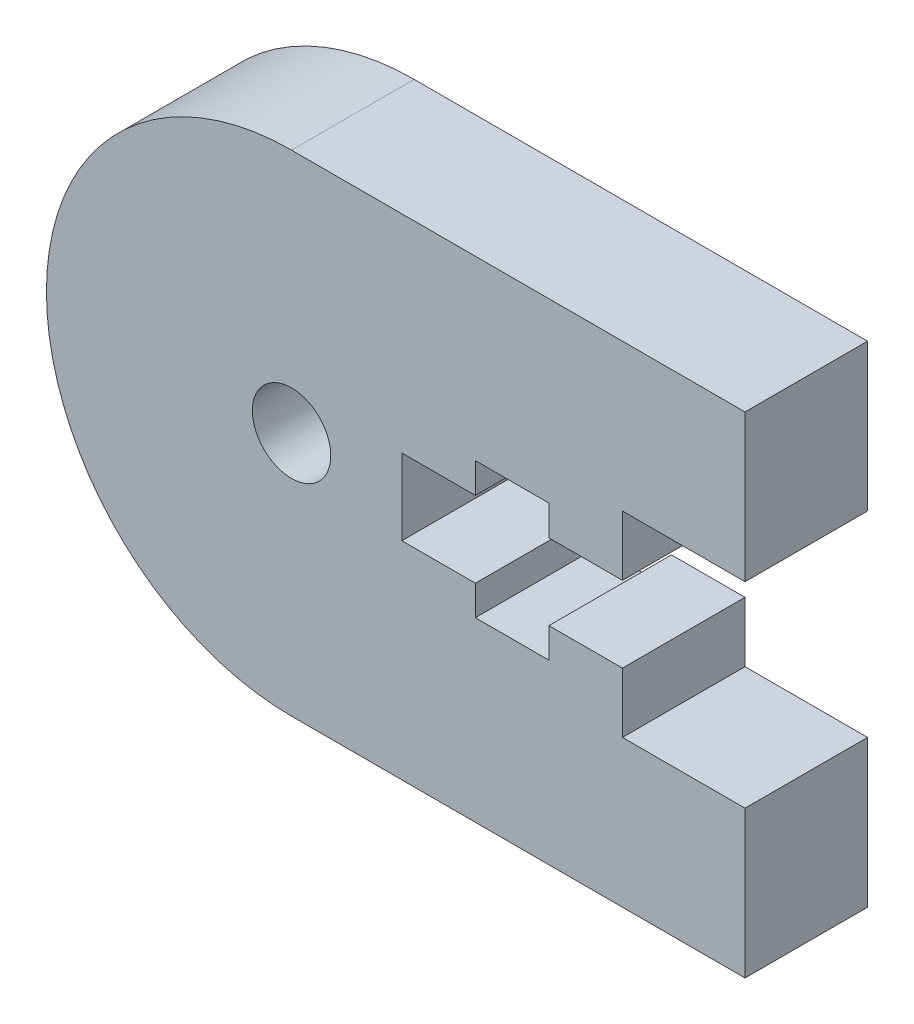
from build123d import *

# Parameters (mm, degrees)
BOSS_EXTRU_1_DEPTH                  = 5
ESQUISSE2_W                         = 5
ESQUISSE2_H                         = 8
ENL_V_MAT_EXTRU_1_DEPTH             = 6
ENL_V_MAT_EXTRU_2_DEPTH             = 2.5
DIAM_TRE_DU_PER_AGE_2_5_2_5_2_D     = 2.5
DIAM_TRE_DU_PER_AGE_2_5_2_5_2_DEPTH = 2.5
ESQUISSE9_W                         = 8.5
ESQUISSE9_H                         = 10
BOSS_EXTRU_2_DEPTH                  = 5
ESQUISSE10_R                        = 1.6
ESQUISSE10_W                        = 9
ESQUISSE10_H                        = 3.1
ESQUISSE10_W_2                      = 3
ESQUISSE10_H_2                      = 5.55
ENL_V_MAT_EXTRU_3_DEPTH             = 6
CHANFREIN1_SIZE                     = 2


with BuildPart() as part:
    # Esquisse1 → Boss.-Extru.1 (new body)
    with BuildSketch(Plane(origin=(0, 0, 0), x_dir=(-1, 0, 0), z_dir=(0, 0, -1))):
        with BuildLine():
            Line((-17, 10), (-17, -10))
            Line((-17, -10), (1.5, -10))
            ThreePointArc((1.5, -10), (11.5, 0), (1.5, 10))
            Line((1.5, 10), (-17, 10))
        make_face()
    extrude(amount=-BOSS_EXTRU_1_DEPTH)

    # Esquisse2 → Enlèv. mat.-Extru.1 (cut, through all)
    with BuildSketch(Plane.XY.offset(5)):
        with Locations((14.5, 0)):
            Rectangle(ESQUISSE2_W, ESQUISSE2_H)
    extrude(amount=-ENL_V_MAT_EXTRU_1_DEPTH, mode=Mode.SUBTRACT)

    # Esquisse3 → Enlèv. mat.-Extru.2 (cut)
    with BuildSketch(Plane.XY.offset(5)):
        with BuildLine():
            Line((-10.160254038, -5), (7, -5))
            Line((7, -5), (7, 5))
            Line((7, 5), (-10.160254038, 5))
            ThreePointArc((-10.160254038, 5), (-11.5, 0), (-10.160254038, -5))
        make_face()
    extrude(amount=-ENL_V_MAT_EXTRU_2_DEPTH, mode=Mode.SUBTRACT)

    # Diamètre du perçage Ø2.5 (2.5)2
    with Locations(Plane.XY.offset(2.5)):
        with Locations((-1.5, 0)):
            Hole(DIAM_TRE_DU_PER_AGE_2_5_2_5_2_D / 2, depth=DIAM_TRE_DU_PER_AGE_2_5_2_5_2_DEPTH)

    # Esquisse9 → Boss.-Extru.2 (add)
    with BuildSketch(Plane.XY.offset(5)):
        with BuildLine():
            Line((-10.160254038, -5), (-1.5, -5))
            Line((-1.5, -5), (-1.5, 5))
            Line((-1.5, 5), (-10.160254038, 5))
            ThreePointArc((-10.160254038, 5), (-11.5, 0), (-10.160254038, -5))
        make_face()
        with Locations((2.75, 0)):
            Rectangle(ESQUISSE9_W, ESQUISSE9_H)
    extrude(amount=-BOSS_EXTRU_2_DEPTH)

    # Esquisse10 → Enlèv. mat.-Extru.3 (cut, through all)
    with BuildSketch(Plane.XY.offset(5)):
        with Locations((-1.5, 0)):
            Circle(ESQUISSE10_R)
        with Locations((7.5, 0)):
            Rectangle(ESQUISSE10_W, ESQUISSE10_H)
        with Locations((7.5, 0.005)):
            Rectangle(ESQUISSE10_W_2, ESQUISSE10_H_2)
    extrude(amount=-ENL_V_MAT_EXTRU_3_DEPTH, mode=Mode.SUBTRACT)

    # Chanfrein1
    chanfrein1_edges = [part.edges().sort_by_distance(p)[0] for p in [
        (-3.1, 0, 0),
    ]]
    chamfer(chanfrein1_edges, length=CHANFREIN1_SIZE)


solid = part.part
